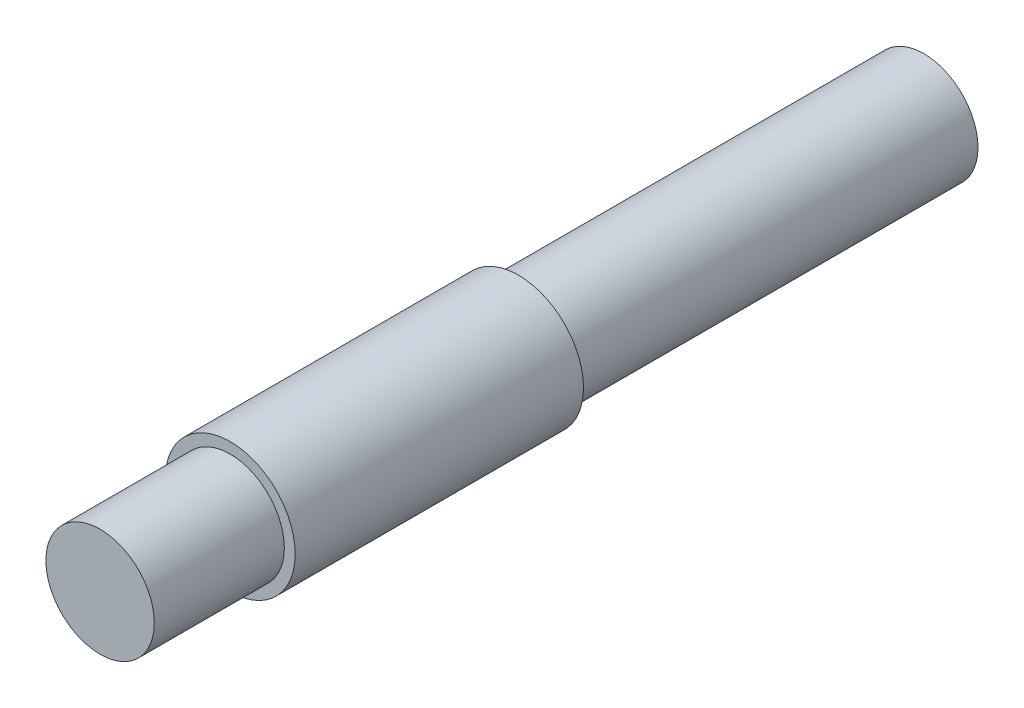
from build123d import *

# Parameters (mm, degrees)
SKETCH_1_R      = 2.5
EXTRUDE_1_DEPTH = 18.7
SKETCH_2_R      = 3
EXTRUDE_2_DEPTH = 13.3
SKETCH_3_R      = 2.5
EXTRUDE_3_DEPTH = 6


with BuildPart() as part:
    # ｽｹｯﾁ1 → ﾎﾞｽ - 押し出し1 (new body)
    with BuildSketch(Plane.XY):
        Circle(SKETCH_1_R)
    extrude(amount=EXTRUDE_1_DEPTH)

    # ｽｹｯﾁ2 → ﾎﾞｽ - 押し出し2 (add)
    with BuildSketch(Plane.XY.offset(18.7)):
        Circle(SKETCH_2_R)
    extrude(amount=EXTRUDE_2_DEPTH)

    # ｽｹｯﾁ3 → ﾎﾞｽ - 押し出し3 (add)
    with BuildSketch(Plane.XY.offset(32)):
        Circle(SKETCH_3_R)
    extrude(amount=EXTRUDE_3_DEPTH)


solid = part.part
